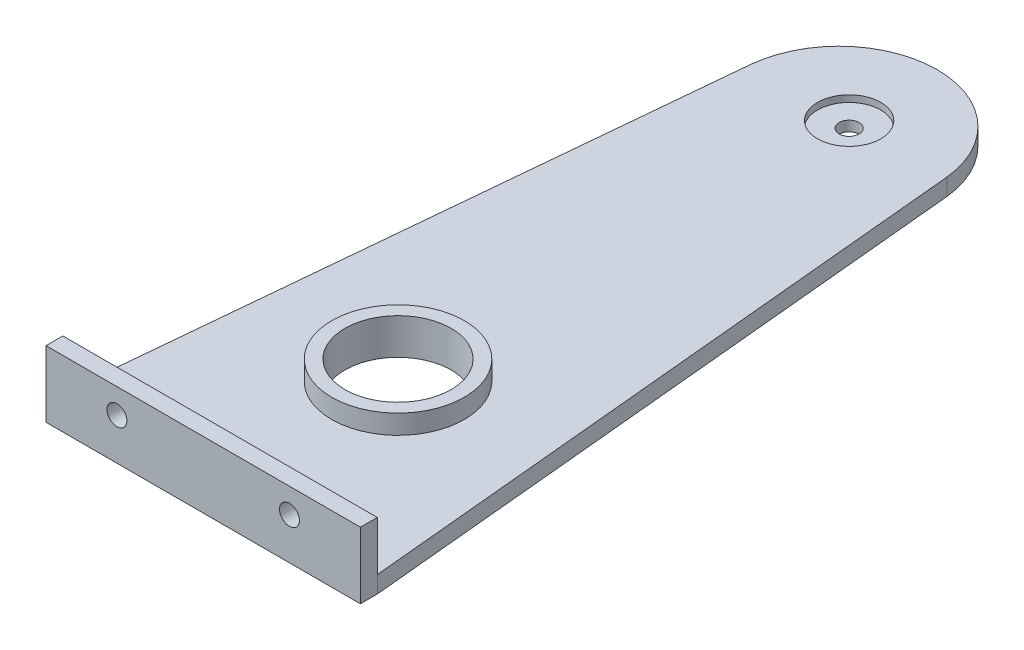
from build123d import *

# Parameters (mm, degrees)
SKETCH2_R           = 1.5
SKETCH2_R_2         = 8
BOSS_EXTRUDE3_DEPTH = 2.54
SKETCH3_W           = 47.380920583
SKETCH3_H           = 10
SKETCH3_R           = 1.5
BOSS_EXTRUDE6_DEPTH = 2.54
SKETCH2_6_R         = 4.7625
SKETCH2_6_R_2       = 1.5
SKETCH2_6_R_3       = 8
SKETCH2_6_R_4       = 6.5
CUT_EXTRUDE2_DEPTH  = 1
SKETCH2_8_R         = 10
SKETCH2_8_R_2       = 8
BOSS_EXTRUDE7_DEPTH = 2.9


with BuildPart() as part:
    # Sketch2 → Boss-Extrude3 (new body)
    with BuildSketch(Plane.XZ):
        with BuildLine():
            Line((14.71851466, 0), (23.68035712, 94.809011723))
            Line((23.68035712, 94.809011723), (-23.700563463, 94.809011723))
            Line((-23.700563463, 94.809011723), (-14.758927346, 0))
            ThreePointArc((-14.758927346, 0), (-0.020206343, -13.282171548), (14.71851466, 0))
        make_face()
        with Locations((-0.020206343, 0)):
            Circle(SKETCH2_R, mode=Mode.SUBTRACT)
        with Locations((-0.000200837, 67.999997057)):
            Circle(SKETCH2_R_2, mode=Mode.SUBTRACT)
    extrude(amount=BOSS_EXTRUDE3_DEPTH)

    # Sketch3 → Boss-Extrude6 (add)
    with BuildSketch(Plane.XY.offset(94.809011723)):
        with Locations((-0.010103172, 2.46)):
            Rectangle(SKETCH3_W, SKETCH3_H)
        with Locations((-13.010103172, 3.73)):
            Circle(SKETCH3_R, mode=Mode.SUBTRACT)
        with Locations((12.989896828, 3.73)):
            Circle(SKETCH3_R, mode=Mode.SUBTRACT)
    extrude(amount=BOSS_EXTRUDE6_DEPTH)

    # Sketch2_6 → Cut-Extrude2 (cut)
    with BuildSketch(Plane.XZ):
        with Locations((-0.020206343, 0)):
            Circle(SKETCH2_6_R)
        with Locations((-0.020206343, 0)):
            Circle(SKETCH2_6_R_2, mode=Mode.SUBTRACT)
        with Locations((-0.000200837, 67.999997057)):
            Circle(SKETCH2_6_R_3)
        with Locations((-0.000200837, 67.999997057)):
            Circle(SKETCH2_6_R_4, mode=Mode.SUBTRACT)
    extrude(amount=CUT_EXTRUDE2_DEPTH, mode=Mode.SUBTRACT)

    # Sketch2_8 → Boss-Extrude7 (add)
    with BuildSketch(Plane.XZ):
        with Locations((-0.000200837, 67.999997057)):
            Circle(SKETCH2_8_R)
        with Locations((-0.000200837, 67.999997057)):
            Circle(SKETCH2_8_R_2, mode=Mode.SUBTRACT)
    extrude(amount=-BOSS_EXTRUDE7_DEPTH)


solid = part.part
